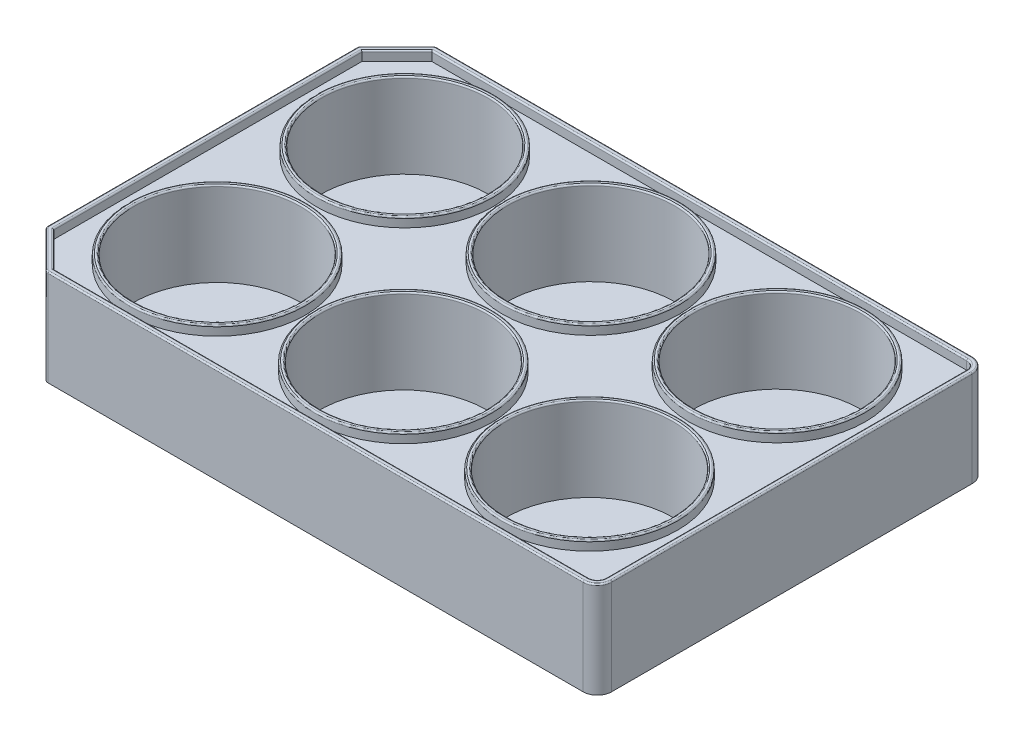
from build123d import *

# Parameters (mm, degrees)
SKETCH1_W           = 123.5
SKETCH1_H           = 81.5
BOSS_EXTRUDE1_DEPTH = 20.16
CHAMFER1_SIZE       = 8
FILLET1_R           = 1
SKETCH2_R           = 17.5
CUT_EXTRUDE1_DEPTH  = 17.7
FILLET2_R           = 3
SKETCH3_R           = 18.5
CUT_EXTRUDE2_DEPTH  = 2
FILLET3_R           = 0.3


with BuildPart() as part:
    # Sketch1 → Boss-Extrude1 (new body)
    with BuildSketch(Plane(origin=(0, 0, 0), x_dir=(1, 0, 0), z_dir=(0, 1, 0))):
        with Locations((61.75, -40.75)):
            Rectangle(SKETCH1_W, SKETCH1_H)
    extrude(amount=BOSS_EXTRUDE1_DEPTH)

    # Chamfer1
    chamfer1_edges = [part.edges().sort_by_distance(p)[0] for p in [
        (0, 10.08, 0),
        (0, 10.08, 81.5),
    ]]
    chamfer(chamfer1_edges, length=CHAMFER1_SIZE)

    # Fillet1
    fillet1_edges = [part.edges().sort_by_distance(p)[0] for p in [
        (0, 10.08, 73.5),
        (0, 10.08, 8),
        (8, 10.08, 0),
        (8, 10.08, 81.5),
    ]]
    fillet(fillet1_edges, radius=FILLET1_R)

    # Sketch2 → Cut-Extrude1 (cut)
    with BuildSketch(Plane(origin=(0, 20.16, 0), x_dir=(1, 0, 0), z_dir=(0, 1, 0))):
        with Locations(Location((22.75, -21.1, 0), (0, 0, 270))):
            Circle(SKETCH2_R)
        with Locations(Location((61.75, -21.1, 0), (0, 0, 270))):
            Circle(SKETCH2_R)
        with Locations(Location((100.75, -21.1, 0), (0, 0, 270))):
            Circle(SKETCH2_R)
        with Locations(Location((61.75, -60.4, 0), (0, 0, 270))):
            Circle(SKETCH2_R)
        with Locations(Location((100.75, -60.4, 0), (0, 0, 270))):
            Circle(SKETCH2_R)
        with Locations(Location((22.75, -60.4, 0), (0, 0, 270))):
            Circle(SKETCH2_R)
    extrude(amount=-CUT_EXTRUDE1_DEPTH, mode=Mode.SUBTRACT)

    # Fillet2
    fillet2_edges = [part.edges().sort_by_distance(p)[0] for p in [
        (123.5, 10.08, 0),
        (123.5, 10.08, 81.5),
    ]]
    fillet(fillet2_edges, radius=FILLET2_R)

    # Sketch3 → Cut-Extrude2 (cut)
    with BuildSketch(Plane(origin=(0, 20.16, 0), x_dir=(1, 0, 0), z_dir=(0, 1, 0))):
        with BuildLine():
            Line((8.476345597, -80.35), (120.5, -80.35))
            ThreePointArc((120.5, -80.35), (121.808147545, -79.808147545), (122.35, -78.5))
            Line((122.35, -78.5), (122.35, -3))
            ThreePointArc((122.35, -3), (121.808147545, -1.691852455), (120.5, -1.15))
            Line((120.5, -1.15), (8.476345597, -1.15))
            Line((8.476345597, -1.15), (1.15, -8.476345597))
            Line((1.15, -8.476345597), (1.15, -73.023654403))
            Line((1.15, -73.023654403), (8.476345597, -80.35))
        make_face()
        with Locations(Location((22.75, -21.1, 0), (0, 0, 270))):
            Circle(SKETCH3_R, mode=Mode.SUBTRACT)
        with Locations(Location((22.75, -60.4, 0), (0, 0, 270))):
            Circle(SKETCH3_R, mode=Mode.SUBTRACT)
        with Locations(Location((61.75, -21.1, 0), (0, 0, 270))):
            Circle(SKETCH3_R, mode=Mode.SUBTRACT)
        with Locations(Location((61.75, -60.4, 0), (0, 0, 270))):
            Circle(SKETCH3_R, mode=Mode.SUBTRACT)
        with Locations(Location((100.75, -21.1, 0), (0, 0, 270))):
            Circle(SKETCH3_R, mode=Mode.SUBTRACT)
        with Locations(Location((100.75, -60.4, 0), (0, 0, 270))):
            Circle(SKETCH3_R, mode=Mode.SUBTRACT)
    extrude(amount=-CUT_EXTRUDE2_DEPTH, mode=Mode.SUBTRACT)

    # Fillet3
    fillet3_edges = [part.edges().sort_by_distance(p)[0] for p in [
        (4.813172798, 20.16, 76.686827202),
        (64.488172798, 20.16, 80.35),
        (121.808147545, 20.16, 79.808147545),
        (122.35, 20.16, 40.75),
        (121.808147545, 20.16, 1.691852455),
        (64.488172798, 20.16, 1.15),
        (4.813172798, 20.16, 4.813172798),
        (1.15, 20.16, 40.75),
        (22.75, 20.16, 2.6),
        (22.75, 20.16, 41.9),
        (61.75, 20.16, 2.6),
        (61.75, 20.16, 41.9),
        (100.75, 20.16, 2.6),
        (100.75, 20.16, 41.9),
        (4, 20.16, 4),
        (0, 20.16, 40.75),
        (4, 20.16, 77.5),
        (64.457106781, 20.16, 81.5),
        (0.076120467, 20.16, 73.46846987),
        (8.03153013, 20.16, 81.423879533),
        (0.076120467, 20.16, 8.03153013),
        (8.03153013, 20.16, 0.076120467),
        (22.75, 20.16, 3.6),
        (61.75, 20.16, 3.6),
        (100.75, 20.16, 3.6),
        (22.75, 20.16, 42.9),
        (100.75, 20.16, 42.9),
        (61.75, 20.16, 42.9),
        (123.5, 20.16, 40.75),
        (64.457106781, 20.16, 0),
        (122.621320344, 20.16, 0.878679656),
        (122.621320344, 20.16, 80.621320344),
    ]]
    fillet(fillet3_edges, radius=FILLET3_R)


solid = part.part
